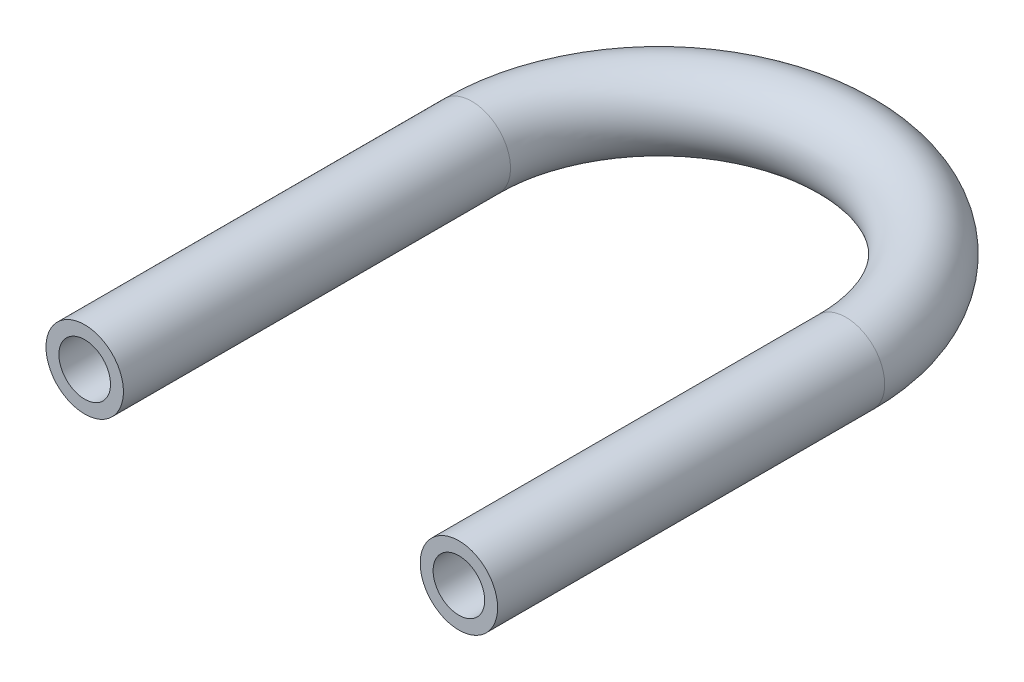
from build123d import *

# Parameters (mm, degrees)
SKETCH2_R   = 3
SKETCH2_R_2 = 2


with BuildPart() as part:
    # Sweep1: sweep along a path in Sketch1
    with BuildLine(Plane(origin=(0, 0, 0), x_dir=(1, 0, 0), z_dir=(0, 1, 0))) as sweep1_path:
        Line((-14.5, -30), (-14.5, 0))
        ThreePointArc((-14.5, 0), (0, 14.5), (14.5, 0))
        Line((14.5, 0), (14.5, -30))
    # Sketch2 → Sweep1 (sweep)
    with BuildSketch(Plane(origin=(-14.5, 0, 30), x_dir=(-1, 0, 0), z_dir=(0, 0, -1))):
        Circle(SKETCH2_R)
        Circle(SKETCH2_R_2, mode=Mode.SUBTRACT)
    sweep(path=sweep1_path.line)


solid = part.part
